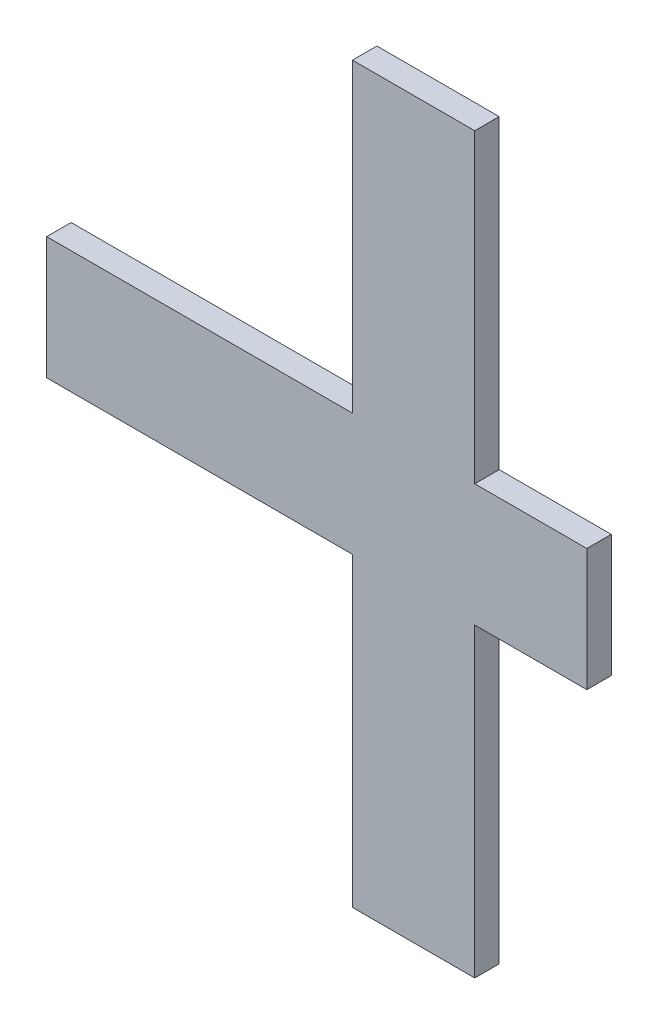
from build123d import *

# Parameters (mm, degrees)
ESBO_O1_W                = 27.5
ESBO_O1_H                = 30
RESSALTO_EXTRUS_O1_DEPTH = 6


with BuildPart() as part:
    # Esboço1 → Ressalto-extrusão1 (new body)
    with BuildSketch(Plane.XY):
        Polygon((75, 75), (75, 0), (105, 0), (105, 75), (105, 105), (105, 180), (90, 180), (75, 180), (75, 105), (0, 105), (0, 75), align=None)
        with Locations((118.75, 90)):
            Rectangle(ESBO_O1_W, ESBO_O1_H)
    extrude(amount=RESSALTO_EXTRUS_O1_DEPTH)


solid = part.part
